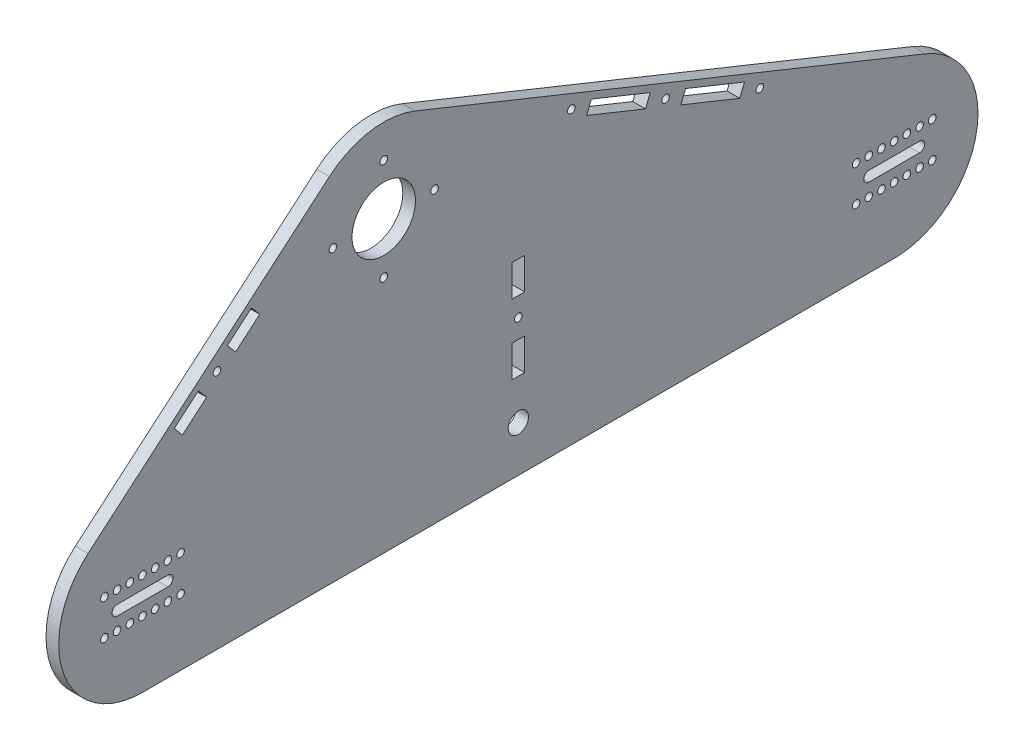
from build123d import *

# Parameters (mm, degrees)
SCHIZZO3_R                   = 1.5
ESTRUSIONE_ESTRUSIONE1_DEPTH = 5
SCHIZZO2_R                   = 2
SCHIZZO2_R_2                 = 12.5
SCHIZZO2_R_3                 = 1.5
TAGLIO_ESTRUSIONE1_DEPTH     = 6
TAGLIO_ESTRUSIONE2_DEPTH     = 6
SCHIZZO6_R                   = 1.5
SCHIZZO6_R_2                 = 4
SCHIZZO6_W                   = 5
SCHIZZO6_H                   = 12.5
TAGLIO_ESTRUSIONE4_DEPTH     = 6


with BuildPart() as part:
    # Schizzo3 → Estrusione-Estrusione1 (new body)
    with BuildSketch(Plane(origin=(0, 0, 0), x_dir=(0, 0, -1), z_dir=(1, 0, 0))):
        with BuildLine():
            Line((-95, -33), (201, -33))
            ThreePointArc((201, -33), (233.396512744, -6.282194046), (213.334616938, 30.608123513))
            Line((213.334616938, 30.608123513), (12.334616938, 111.608123513))
            ThreePointArc((12.334616938, 111.608123513), (-5.305430843, 113.570729245), (-21.410737295, 106.111358555))
            Line((-21.410737295, 106.111358555), (-116.410737295, 25.111358555))
            ThreePointArc((-116.410737295, 25.111358555), (-125.96509997, -11.408881796), (-95, -33))
        make_face()
        with Locations((-65.666686189, 61.806607259)):
            Circle(SCHIZZO3_R, mode=Mode.SUBTRACT)
        with Locations((110.965735584, 66.470529041)):
            Circle(SCHIZZO3_R, mode=Mode.SUBTRACT)
        with Locations((73.86497981, 81.421579875)):
            Circle(SCHIZZO3_R, mode=Mode.SUBTRACT)
        with Locations((148.066491357, 51.519478207)):
            Circle(SCHIZZO3_R, mode=Mode.SUBTRACT)
    extrude(amount=ESTRUSIONE_ESTRUSIONE1_DEPTH)

    # Schizzo2 → Taglio-Estrusione1 (cut, through all)
    with BuildSketch(Plane(origin=(0, 0, 0), x_dir=(0, 0, -1), z_dir=(1, 0, 0))):
        with Locations((-95, 0)):
            Circle(SCHIZZO2_R)
        with Locations((201, 0)):
            Circle(SCHIZZO2_R)
        with Locations((0, 81)):
            Circle(SCHIZZO2_R_2)
        with Locations((0, 101)):
            Circle(SCHIZZO2_R_3)
        with Locations((20, 81)):
            Circle(SCHIZZO2_R_3)
        with Locations((-20, 81)):
            Circle(SCHIZZO2_R_3)
        with Locations((0, 61)):
            Circle(SCHIZZO2_R_3)
    extrude(amount=TAGLIO_ESTRUSIONE1_DEPTH, mode=Mode.SUBTRACT)

    # Schizzo4 → Taglio-Estrusione2 (cut, through all)
    with BuildSketch(Plane(origin=(0, 0, 0), x_dir=(0, 0, -1), z_dir=(1, 0, 0))):
        Polygon((104.943784553, 71.592648309), (103.074903199, 66.955053837), (79.886930841, 76.299460608), (81.755812195, 80.93705508), align=None)
        Polygon((118.856567968, 65.986004246), (116.987686614, 61.348409774), (140.175658973, 52.004003003), (142.044540327, 56.641597475), align=None)
        Polygon((-82.507716927, 50.732778486), (-72.995838686, 58.842906249), (-69.751787581, 55.038154953), (-79.263665822, 46.92802719), align=None)
        Polygon((-61.581584798, 68.575059565), (-58.337533692, 64.770308269), (-48.825655452, 72.880436032), (-52.069706557, 76.685187328), align=None)
    extrude(amount=TAGLIO_ESTRUSIONE2_DEPTH, mode=Mode.SUBTRACT)

    # Schizzo6 → Taglio-Estrusione4 (cut, through all)
    with BuildSketch(Plane(origin=(0, 0, 0), x_dir=(0, 0, -1), z_dir=(1, 0, 0))):
        with Locations((-95, 7)):
            Circle(SCHIZZO6_R)
        with Locations((-90, 7)):
            Circle(SCHIZZO6_R)
        with Locations((-85, 7)):
            Circle(SCHIZZO6_R)
        with Locations((-80, 7)):
            Circle(SCHIZZO6_R)
        with Locations((53, -15)):
            Circle(SCHIZZO6_R_2)
        with Locations((53, 20.84)):
            Circle(SCHIZZO6_R)
        with Locations((-100, 7)):
            Circle(SCHIZZO6_R)
        with Locations((-105, 7)):
            Circle(SCHIZZO6_R)
        with Locations((-110, 7)):
            Circle(SCHIZZO6_R)
        with Locations((-80, -7)):
            Circle(SCHIZZO6_R)
        with Locations((-85, -7)):
            Circle(SCHIZZO6_R)
        with Locations((-90, -7)):
            Circle(SCHIZZO6_R)
        with Locations((-95, -7)):
            Circle(SCHIZZO6_R)
        with Locations((-100, -7)):
            Circle(SCHIZZO6_R)
        with Locations((-105, -7)):
            Circle(SCHIZZO6_R)
        with Locations((-110, -7)):
            Circle(SCHIZZO6_R)
        with Locations((216, -7)):
            Circle(SCHIZZO6_R)
        with Locations((211, -7)):
            Circle(SCHIZZO6_R)
        with Locations((206, -7)):
            Circle(SCHIZZO6_R)
        with Locations((201, -7)):
            Circle(SCHIZZO6_R)
        with Locations((196, -7)):
            Circle(SCHIZZO6_R)
        with Locations((191, -7)):
            Circle(SCHIZZO6_R)
        with Locations((186, -7)):
            Circle(SCHIZZO6_R)
        with Locations((186, 7)):
            Circle(SCHIZZO6_R)
        with Locations((191, 7)):
            Circle(SCHIZZO6_R)
        with Locations((196, 7)):
            Circle(SCHIZZO6_R)
        with Locations((201, 7)):
            Circle(SCHIZZO6_R)
        with Locations((206, 7)):
            Circle(SCHIZZO6_R)
        with Locations((211, 7)):
            Circle(SCHIZZO6_R)
        with Locations((216, 7)):
            Circle(SCHIZZO6_R)
        with BuildLine():
            Line((-105, 2), (-85, 2))
            ThreePointArc((-85, 2), (-83, 0), (-85, -2))
            Line((-85, -2), (-105, -2))
            ThreePointArc((-105, -2), (-107, 0), (-105, 2))
        make_face()
        with BuildLine():
            Line((191, 2), (211, 2))
            ThreePointArc((211, 2), (213, 0), (211, -2))
            Line((211, -2), (191, -2))
            ThreePointArc((191, -2), (189, 0), (191, 2))
        make_face()
        with Locations((53, 34.59)):
            Rectangle(SCHIZZO6_W, SCHIZZO6_H)
        with Locations((53, 7.09)):
            Rectangle(SCHIZZO6_W, SCHIZZO6_H)
    extrude(amount=TAGLIO_ESTRUSIONE4_DEPTH, mode=Mode.SUBTRACT)


solid = part.part
